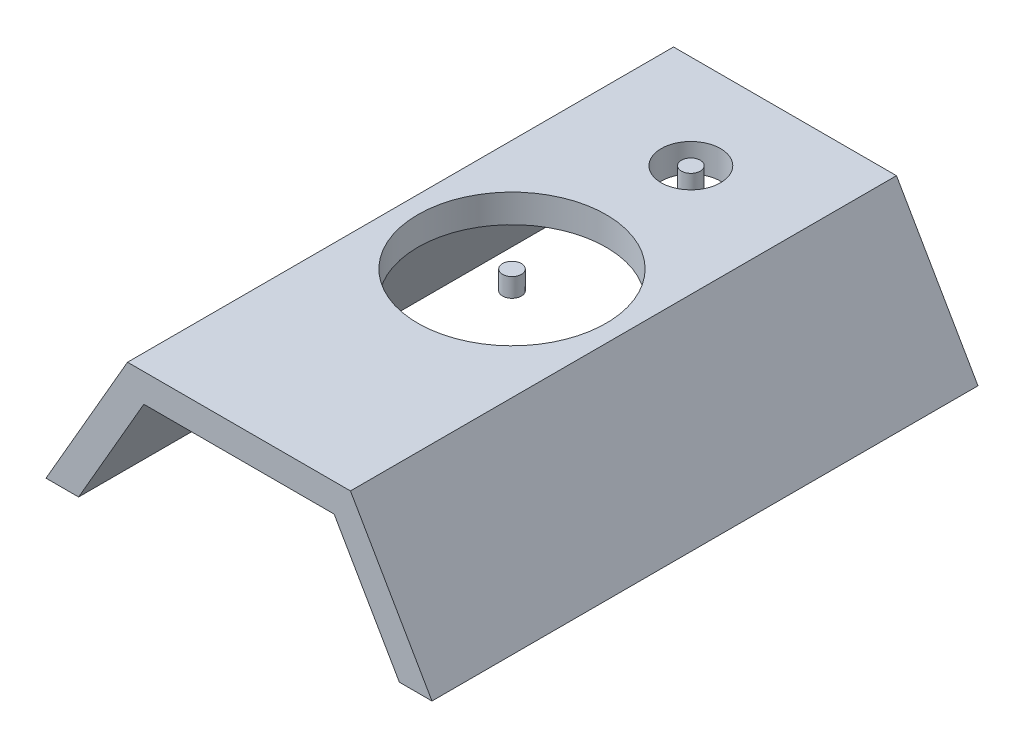
from build123d import *

# Parameters (mm, degrees)
BOSS_EXTRU_1_DEPTH      = 580
ENL_V_MAT_EXTRU_1_REACH = 152
ESQUISSE2_R             = 100
ESQUISSE2_R_2           = 31.5
ESQUISSE4_R             = 10
BOSS_EXTRU_2_DEPTH      = 20
ESQUISSE5_R             = 10
BOSS_EXTRU_3_DEPTH      = 20


with BuildPart() as part:
    # Esquisse1 → Boss.-Extru.1 (new body)
    with BuildSketch(Plane.XY):
        Polygon((236.807621582, 30), (0, 30), (-86.592378418, -120), (-51.955427051, -120), (17.318475684, 0), (219.489145899, 0), (288.763048633, -120), (323.407621582, -120), align=None)
    extrude(amount=BOSS_EXTRU_1_DEPTH)

    # Esquisse2 → Enlèv. mat.-Extru.1 (cut, up to next)
    with BuildSketch(Plane(origin=(0, 30, 0), x_dir=(1, 0, 0), z_dir=(0, 1, 0)), mode=Mode.PRIVATE) as enl_v_mat_extru_1_sk1:
        with Locations((118.403810791, -290)):
            Circle(ESQUISSE2_R)
    enl_v_mat_extru_1_tool1 = extrude(enl_v_mat_extru_1_sk1.sketch, amount=-ENL_V_MAT_EXTRU_1_REACH, mode=Mode.PRIVATE) & part.part
    add(enl_v_mat_extru_1_tool1.solids().sort_by_distance((118.403811, 30, 290))[0], mode=Mode.SUBTRACT)
    # Esquisse2 → Enlèv. mat.-Extru.1 (cut, up to next)
    with BuildSketch(Plane(origin=(0, 30, 0), x_dir=(1, 0, 0), z_dir=(0, 1, 0)), mode=Mode.PRIVATE) as enl_v_mat_extru_1_sk2:
        with Locations((118.403810791, -100)):
            Circle(ESQUISSE2_R_2)
    enl_v_mat_extru_1_tool2 = extrude(enl_v_mat_extru_1_sk2.sketch, amount=-ENL_V_MAT_EXTRU_1_REACH, mode=Mode.PRIVATE) & part.part
    add(enl_v_mat_extru_1_tool2.solids().sort_by_distance((118.403811, 30, 100))[0], mode=Mode.SUBTRACT)


with BuildPart() as body_2:
    # Esquisse4 → Boss.-Extru.2 (new body)
    with BuildSketch(Plane(origin=(0, 30, 0), x_dir=(1, 0, 0), z_dir=(0, 1, 0))):
        with Locations((118.403810791, -290)):
            Circle(ESQUISSE4_R)
    extrude(amount=-BOSS_EXTRU_2_DEPTH)


with BuildPart() as body_3:
    # Esquisse5 → Boss.-Extru.3 (new body)
    with BuildSketch(Plane(origin=(0, 30, 0), x_dir=(1, 0, 0), z_dir=(0, 1, 0))):
        with Locations((118.403810791, -100)):
            Circle(ESQUISSE5_R)
    extrude(amount=-BOSS_EXTRU_3_DEPTH)


solid = Compound([part.part, body_2.part, body_3.part])
